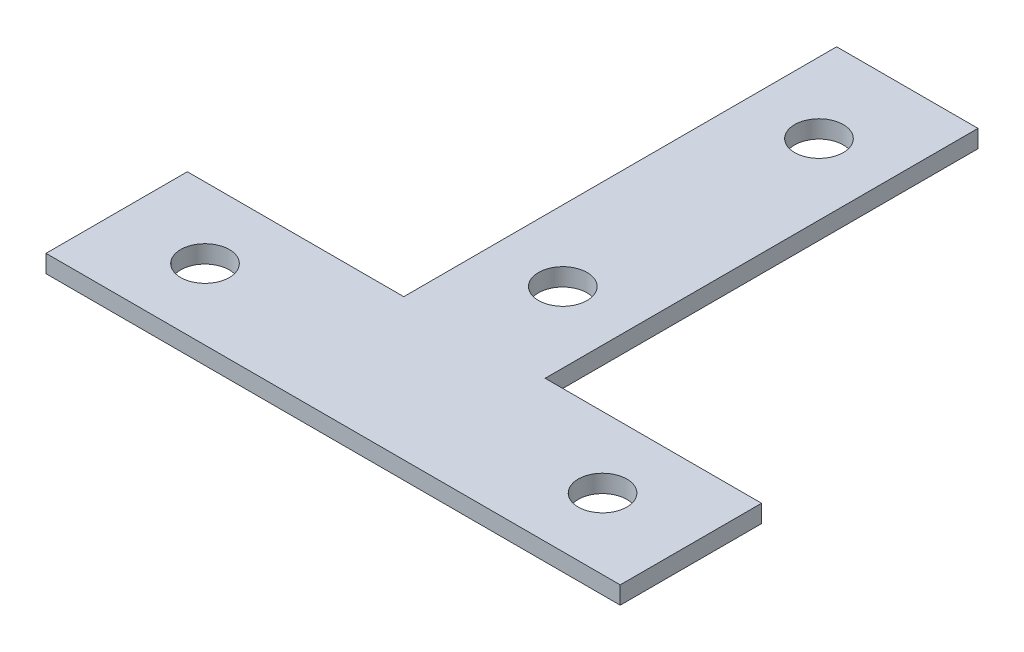
from build123d import *

# Parameters (mm, degrees)
SKETCH_1_R      = 2.75
EXTRUDE_1_DEPTH = 2


with BuildPart() as part:
    # 草图1 → 凸台-拉伸1 (new body)
    with BuildSketch(Plane(origin=(0, 0, 0), x_dir=(1, 0, 0), z_dir=(0, 1, 0))):
        Polygon((0, 0), (65, 0), (65, 16), (40.5, 16), (40.5, 65), (24.5, 65), (24.5, 16), (0, 16), align=None)
        with Locations((10, 8)):
            Circle(SKETCH_1_R, mode=Mode.SUBTRACT)
        with Locations((55, 8)):
            Circle(SKETCH_1_R, mode=Mode.SUBTRACT)
        with Locations((32.5, 55)):
            Circle(SKETCH_1_R, mode=Mode.SUBTRACT)
        with Locations((32.5, 26)):
            Circle(SKETCH_1_R, mode=Mode.SUBTRACT)
    extrude(amount=EXTRUDE_1_DEPTH)


solid = part.part
